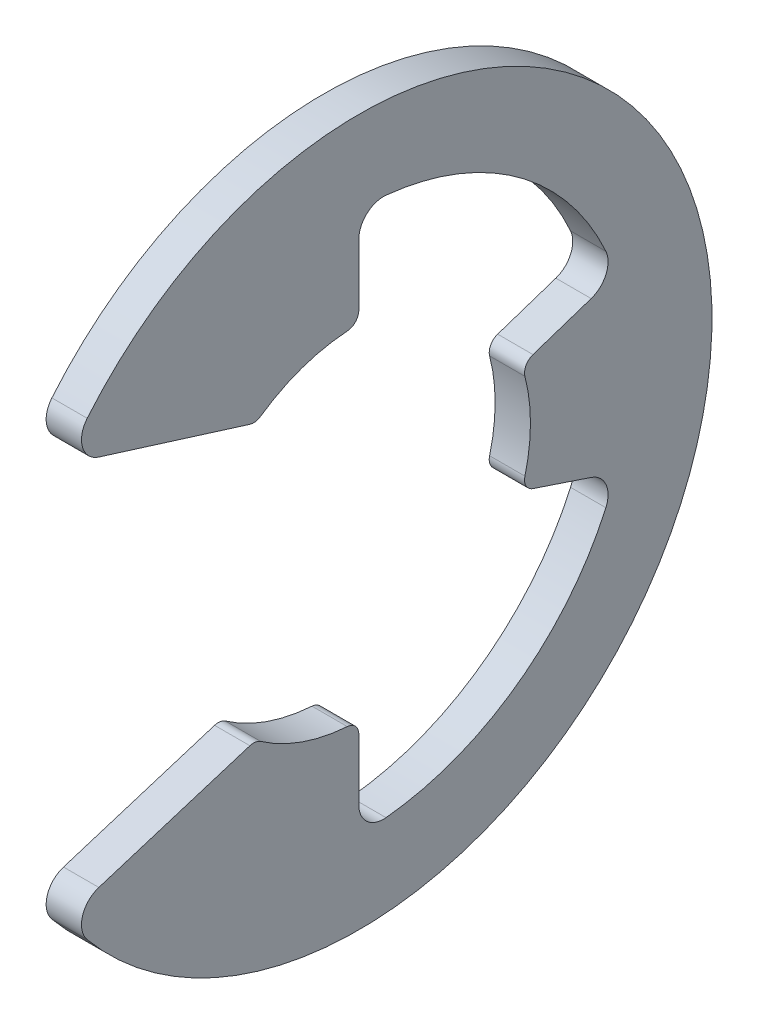
from build123d import *

# Parameters (mm, degrees)
BOSS_EXTRUDE1_DEPTH      = 0.3175
BOSS_EXTRUDE1_DEPTH_BACK = 0.3175
FILLET1_R                = 0.4445
FILLET2_R                = 0.22225


with BuildPart() as part:
    # Sketch3 → Boss-Extrude1 (new body, two sides)
    with BuildSketch(Plane(origin=(0, 0, 0), x_dir=(0, 0, -1), z_dir=(1, 0, 0))) as boss_extrude1_sk:
        with BuildLine():
            Line((2.927731526, -0.975910509), (4.620320242, -1.540106747))
            ThreePointArc((4.620320242, -1.540106747), (2.847682435, -3.950948327), (0, -4.870245161))
            Line((0, -4.870245161), (0, -3.0861))
            ThreePointArc((0, -3.0861), (-0.975910509, -2.927731526), (-1.85166, -2.46888))
            Line((-1.85166, -2.46888), (-5.273248683, -3.537703821))
            ThreePointArc((-5.273248683, -3.537703821), (6.35, 0), (-5.273248683, 3.537703821))
            Line((-5.273248683, 3.537703821), (-1.85166, 2.46888))
            ThreePointArc((-1.85166, 2.46888), (-0.975910509, 2.927731526), (0, 3.0861))
            Line((0, 3.0861), (0, 4.870245161))
            ThreePointArc((0, 4.870245161), (2.847682435, 3.950948327), (4.620320242, 1.540106747))
            Line((4.620320242, 1.540106747), (2.927731526, 0.975910509))
            ThreePointArc((2.927731526, 0.975910509), (3.0861, 0), (2.927731526, -0.975910509))
        make_face()
    extrude(amount=BOSS_EXTRUDE1_DEPTH)
    extrude(boss_extrude1_sk.sketch, amount=-BOSS_EXTRUDE1_DEPTH_BACK)

    # Fillet1
    fillet1_edges = [part.edges().sort_by_distance(p)[0] for p in [
        (0, 1.540106747, -4.620320242),
        (0, 4.870245161, 0),
        (0, 3.537703821, 5.273248683),
        (0, -3.537703821, 5.273248683),
        (0, -4.870245161, 0),
        (0, -1.540106747, -4.620320242),
    ]]
    fillet(fillet1_edges, radius=FILLET1_R)

    # Fillet2
    fillet2_edges = [part.edges().sort_by_distance(p)[0] for p in [
        (0, 0.975910509, -2.927731526),
        (0, 3.0861, 0),
        (0, 2.46888, 1.85166),
        (0, -2.46888, 1.85166),
        (0, -3.0861, 0),
        (0, -0.975910509, -2.927731526),
    ]]
    fillet(fillet2_edges, radius=FILLET2_R)


solid = part.part
